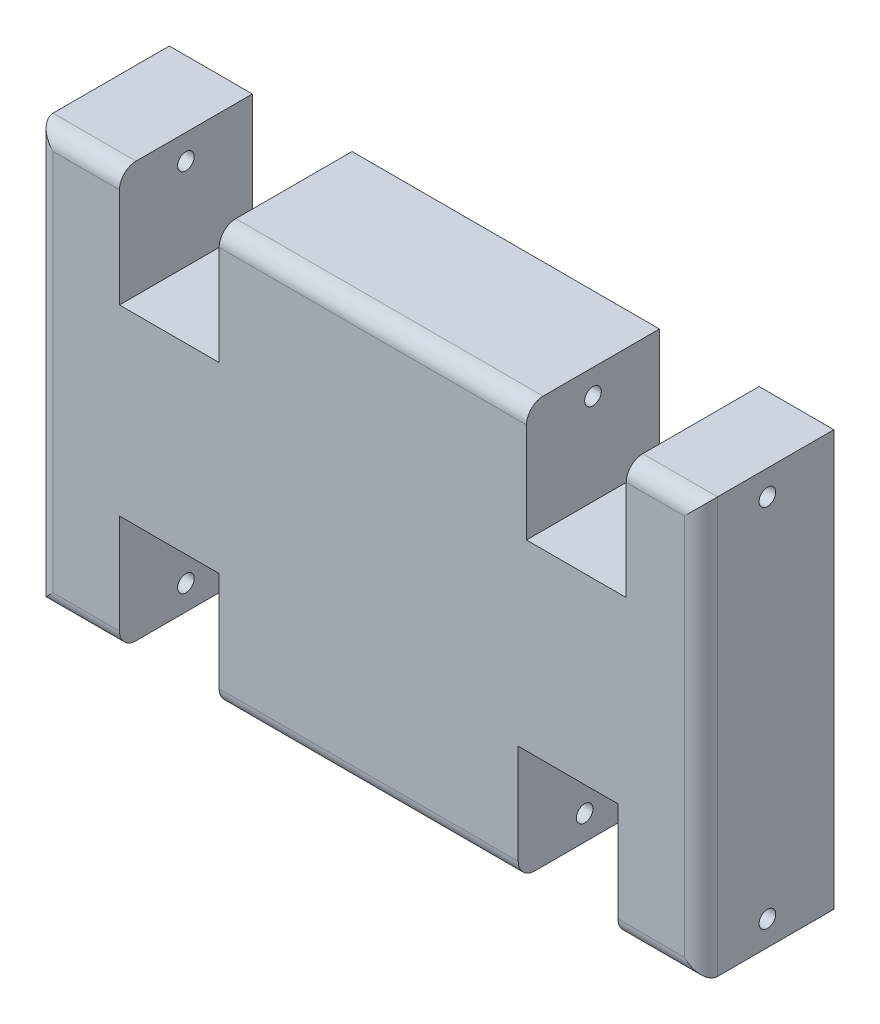
from build123d import *

# Parameters (mm, degrees)
SALIENTE_EXTRUIR2_DEPTH = 8
CROQUIS3_R              = 0.5
CORTAR_EXTRUIR1_DEPTH   = 45
REDONDEO1_R             = 1
REDONDEO2_R             = 1
REDONDEO3_R             = 1
REDONDEO4_R             = 1


with BuildPart() as part:
    # Croquis1 → Saliente-Extruir2 (new body)
    with BuildSketch(Plane.XY):
        Polygon((0, 0), (5, 0), (5, 7), (11, 7), (11, 0), (29, 0), (29, 7), (35, 7), (35, 0), (40, 0), (40, 25), (35.5, 25), (35.5, 18), (29.5, 18), (29.5, 25), (11, 25), (11, 18), (5, 18), (5, 25), (0, 25), align=None)
    extrude(amount=SALIENTE_EXTRUIR2_DEPTH)

    # Croquis3 → Cortar-Extruir1 (cut)
    with BuildSketch(Plane(origin=(40, 0, 0), x_dir=(0, 0, -1), z_dir=(1, 0, 0))):
        with Locations((-4, 23.498247599)):
            Circle(CROQUIS3_R)
        with Locations((-4, 1.501752401)):
            Circle(CROQUIS3_R)
    extrude(amount=-CORTAR_EXTRUIR1_DEPTH, mode=Mode.SUBTRACT)

    # Redondeo1
    redondeo1_edges = [part.edges().sort_by_distance(p)[0] for p in [
        (20, 0, 8),
    ]]
    fillet(redondeo1_edges, radius=REDONDEO1_R)

    # Redondeo2
    redondeo2_edges = [part.edges().sort_by_distance(p)[0] for p in [
        (37.5, 0, 8),
        (40, 12.5, 8),
        (37.75, 25, 8),
    ]]
    fillet(redondeo2_edges, radius=REDONDEO2_R)

    # Redondeo3
    redondeo3_edges = [part.edges().sort_by_distance(p)[0] for p in [
        (20.25, 25, 8),
    ]]
    fillet(redondeo3_edges, radius=REDONDEO3_R)

    # Redondeo4
    redondeo4_edges = [part.edges().sort_by_distance(p)[0] for p in [
        (0, 12.5, 8),
        (2.5, 25, 8),
        (2.5, 0, 8),
    ]]
    fillet(redondeo4_edges, radius=REDONDEO4_R)


solid = part.part
